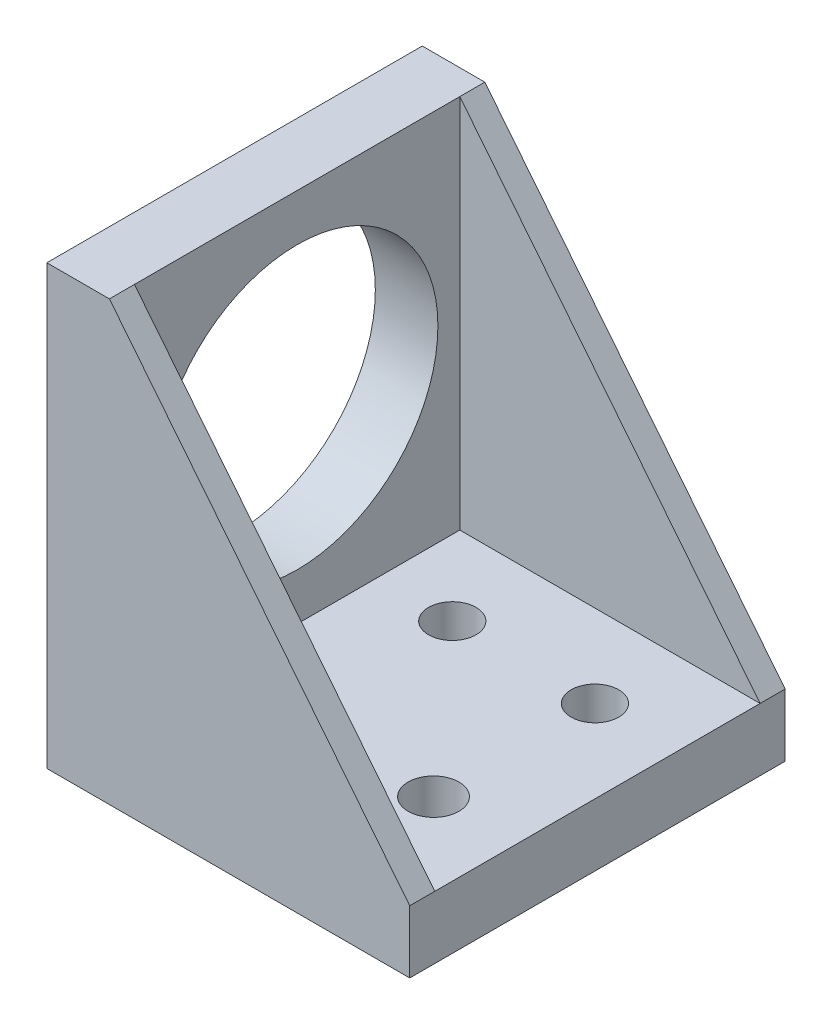
from build123d import *

# Parameters (mm, degrees)
SKETCH1_W           = 38.1
SKETCH1_H           = 6.35
BOSS_EXTRUDE1_DEPTH = 30.48
SKETCH1_3_W         = 38.1
SKETCH1_3_H         = 38.1
SKETCH1_3_R         = 14.2875
BOSS_EXTRUDE2_DEPTH = 6.35
SKETCH3_W           = 6.35
SKETCH3_H           = 38.1
BOSS_EXTRUDE3_DEPTH = 6.35
BOSS_EXTRUDE4_DEPTH = 2.54
BOSS_EXTRUDE5_DEPTH = 2.54
SKETCH6_R           = 2.413
SKETCH6_R_2         = 2.5796875
CUT_EXTRUDE1_DEPTH  = 53.378840193


with BuildPart() as part:
    # Sketch1 → Boss-Extrude1 (new body)
    with BuildSketch(Plane(origin=(0, 0, 0), x_dir=(0, 0, -1), z_dir=(1, 0, 0))):
        with Locations((0, -22.225)):
            Rectangle(SKETCH1_W, SKETCH1_H)
    extrude(amount=BOSS_EXTRUDE1_DEPTH)



with BuildPart() as body_2:
    # Sketch1_3 → Boss-Extrude2 (new body)
    with BuildSketch(Plane(origin=(0, 0, 0), x_dir=(0, 0, -1), z_dir=(1, 0, 0))):
        Rectangle(SKETCH1_3_W, SKETCH1_3_H)
        Circle(SKETCH1_3_R, mode=Mode.SUBTRACT)
    extrude(amount=-BOSS_EXTRUDE2_DEPTH)


with BuildPart() as part_1:
    add(part.part)

    add(body_2.part)  # Boss-Extrude3 merges body 2
    # Sketch3 → Boss-Extrude3 (add)
    with BuildSketch(Plane.XZ.offset(19.05)):
        with Locations((-3.175, 0)):
            Rectangle(SKETCH3_W, SKETCH3_H)
    extrude(amount=BOSS_EXTRUDE3_DEPTH)

    # Sketch4 → Boss-Extrude4 (add)
    with BuildSketch(Plane.XY.offset(19.05)):
        Polygon((0, 19.05), (30.48, -19.05), (0, -19.05), align=None)
    extrude(amount=-BOSS_EXTRUDE4_DEPTH)

    # Sketch5 → Boss-Extrude5 (add)
    with BuildSketch(Plane(origin=(0, 0, -19.05), x_dir=(-1, 0, 0), z_dir=(0, 0, -1))):
        Polygon((0, 19.05), (-30.48, -19.05), (0, -19.05), align=None)
    extrude(amount=-BOSS_EXTRUDE5_DEPTH)

    # Sketch6 → Cut-Extrude1 (cut, through all)
    with BuildSketch(Plane(origin=(0, -19.05, 0), x_dir=(1, 0, 0), z_dir=(0, 1, 0))):
        with Locations((7.62, 8.128)):
            Circle(SKETCH6_R)
        with Locations((22.098, 8.128)):
            Circle(SKETCH6_R)
        with Locations((7.62, -8.255)):
            Circle(SKETCH6_R)
        with Locations((22.098, -8.255)):
            Circle(SKETCH6_R_2)
    extrude(amount=-CUT_EXTRUDE1_DEPTH, mode=Mode.SUBTRACT)


solid = part_1.part
